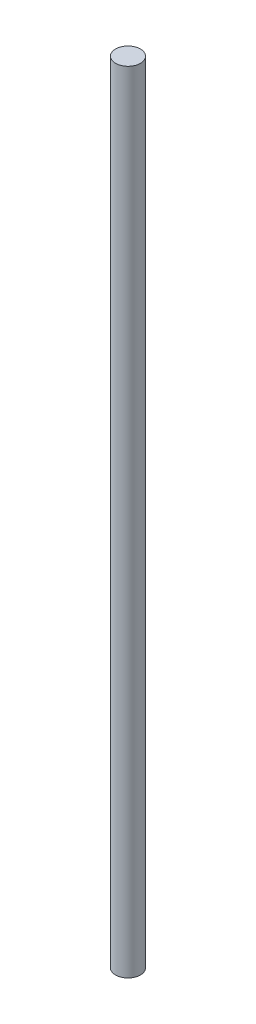
from build123d import *

# Parameters (mm, degrees)
SKETCH1_R           = 4
BOSS_EXTRUDE1_DEPTH = 254


with BuildPart() as part:
    # Sketch1 → Boss-Extrude1 (new body)
    with BuildSketch(Plane(origin=(0, 0, 0), x_dir=(1, 0, 0), z_dir=(0, 1, 0))):
        Circle(SKETCH1_R)
    extrude(amount=BOSS_EXTRUDE1_DEPTH)


solid = part.part
